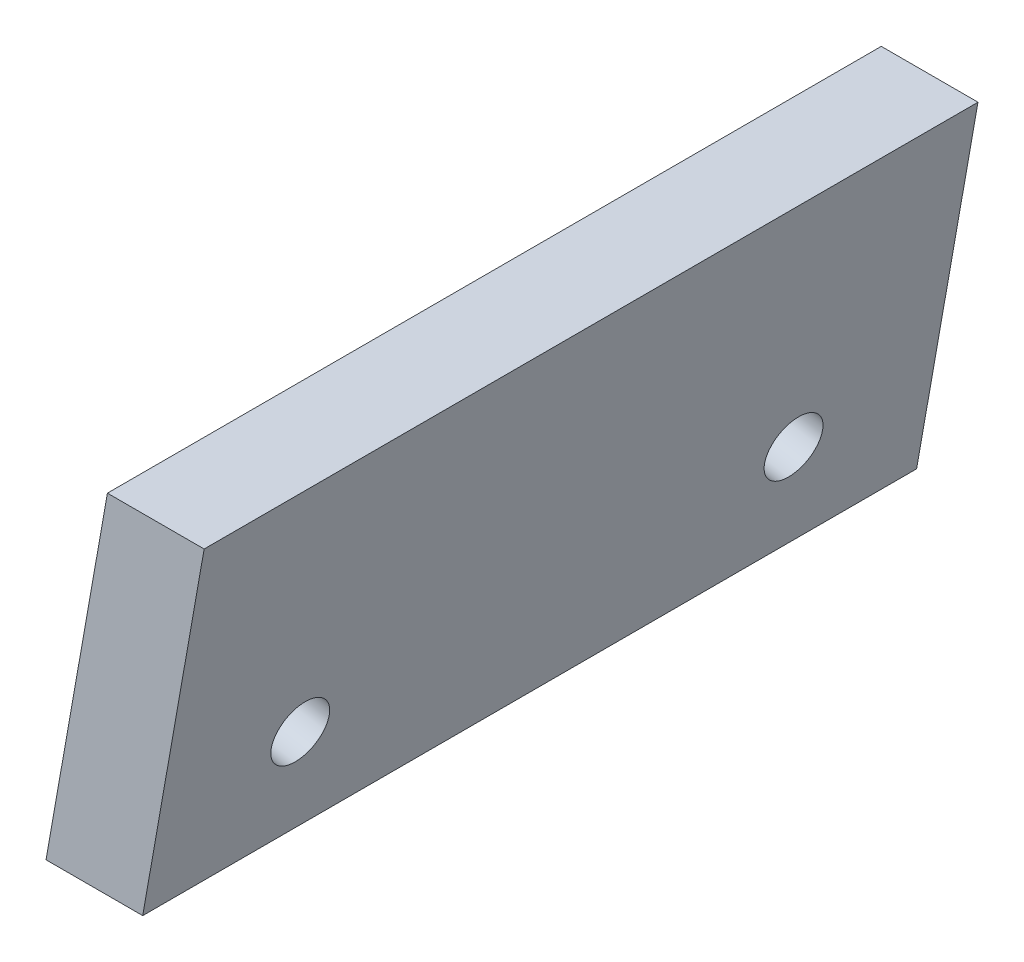
from build123d import *

# Parameters (mm, degrees)
BOSS_EXTRUDE2_DEPTH = 20
SKETCH4_R           = 0.75
CUT_EXTRUDE1_DEPTH  = 5.024852982


with BuildPart() as part:
    # Sketch2 → Boss-Extrude2 (new body)
    with BuildSketch(Plane.XY):
        Polygon((0, 0), (2.5, 0), (4.086942826, 9), (1.586942826, 9), align=None)
    extrude(amount=BOSS_EXTRUDE2_DEPTH)

    # Sketch4 → Cut-Extrude1 (cut, through all)
    with BuildSketch(Plane(origin=(0, 0, 0), x_dir=(0, 0, 1), z_dir=(-0.984807753, 0.173648178, 0))):
        with Locations((3.625, 3)):
            Circle(SKETCH4_R)
        with Locations((16.375, 3)):
            Circle(SKETCH4_R)
    extrude(amount=-CUT_EXTRUDE1_DEPTH, mode=Mode.SUBTRACT)


solid = part.part
